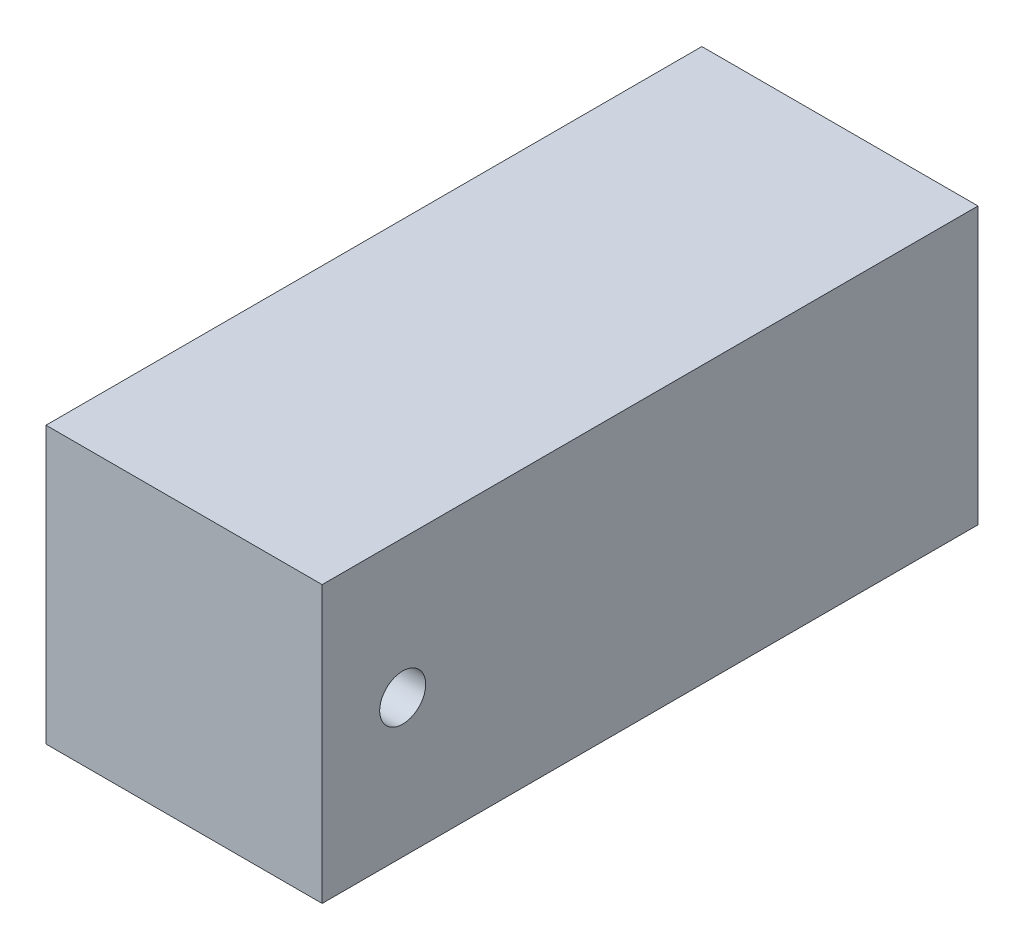
from build123d import *

# Parameters (mm, degrees)
SKETCH1_W           = 76.2
SKETCH1_H           = 180.975
BOSS_EXTRUDE1_DEPTH = 76.2
SKETCH2_R           = 6.35
CUT_EXTRUDE1_DEPTH  = 76.2


with BuildPart() as part:
    # Sketch1 → Boss-Extrude1 (new body)
    with BuildSketch(Plane(origin=(0, 0, 0), x_dir=(1, 0, 0), z_dir=(0, 1, 0))):
        Rectangle(SKETCH1_W, SKETCH1_H)
    extrude(amount=BOSS_EXTRUDE1_DEPTH)

    # Sketch2 → Cut-Extrude1 (cut)
    with BuildSketch(Plane(origin=(38.1, 0, 0), x_dir=(0, 0, -1), z_dir=(1, 0, 0))):
        with Locations((-68.2625, 38.1)):
            Circle(SKETCH2_R)
    extrude(amount=-CUT_EXTRUDE1_DEPTH, mode=Mode.SUBTRACT)


solid = part.part
